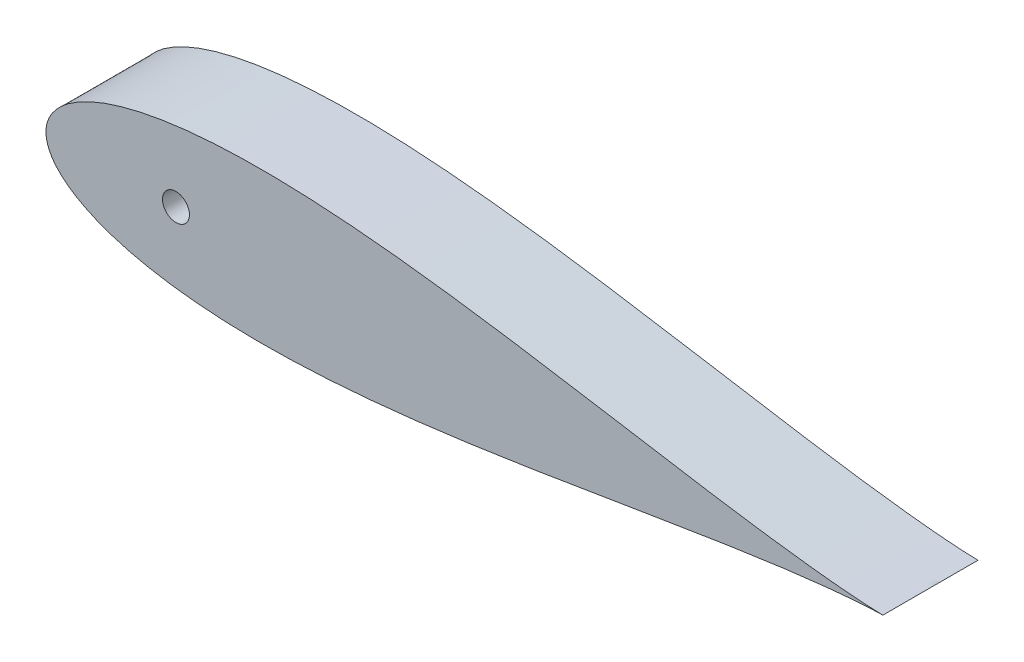
from build123d import *

# Parameters (mm, degrees)
BOSS_EXTRUDE1_DEPTH     = 76.2
SKETCH3_R               = 10.795
CUT_EXTRUDE2_DEPTH      = 76.2
SKETCH6_R               = 6.35
CUT_EXTRUDE3_DEPTH      = 53.34
CUT_EXTRUDE3_DEPTH_BACK = 0.000254
SKETCH7_R               = 1.5875
CUT_EXTRUDE4_DEPTH      = 30.48


with BuildPart() as part:
    # Sketch1 → Boss-Extrude1 (new body)
    with BuildSketch(Plane.XY):
        with BuildLine():
            Line((643.966787522, 0), (643.599082689, 0))
            Line((643.599082689, 0), (643.599082689, -1.016))
            ThreePointArc((643.599082689, -1.016), (643.872033494, -0.540245973), (643.966787522, 0))
        make_face()
        with BuildLine():
            Line((643.599082689, -1.016), (643.599082689, 0))
            Line((643.599082689, 0), (641.567082689, 0))
            ThreePointArc((641.567082689, 0), (642.269121423, -1.135922533), (643.599082689, -1.016))
        make_face()
        with BuildLine():
            Line((641.567082689, 0), (643.599082689, 0))
            Line((643.599082689, 0), (643.966787522, 0))
            ThreePointArc((643.966787522, 0), (643.547407924, 1.075012082), (642.510849283, 1.582039112))
            add(Edge.make_bspline(
                [(642.510849283, 1.582039112), (641.993392355, 1.625070631), (638.093728429, 1.953546407), (630.413817462, 2.663385493), (619.014124193, 3.849253664), (606.374988512, 5.304428983), (592.543922516, 7.037634907), (577.585454095, 9.050636147), (561.564270734, 11.338919625), (544.549749946, 13.890665375), (526.614143658, 16.687720753), (507.832591566, 19.705111663), (488.282710288, 22.911672601), (468.044367735, 26.27043606), (447.199424328, 29.739007432), (425.831595832, 33.270324121), (404.02631566, 36.813220545), (381.870662856, 40.313266856), (359.453314895, 43.713502532), (336.86454415, 46.955447457), (314.196207315, 49.979843895), (291.541767704, 52.727712704), (268.996310773, 55.141201012), (246.65655865, 57.164603829), (224.620860897, 58.745176641), (202.989192599, 59.8341217), (181.863132616, 60.387506142), (161.345829027, 60.366961324), (141.542033828, 59.739895824), (122.558104573, 58.481758104), (104.502313427, 56.574303932), (87.485018636, 54.008935199), (71.619696083, 50.784752003), (57.023709725, 46.912543066), (43.82045433, 42.41500246), (32.141645239, 37.332204029), (22.129107375, 31.731455339), (13.932423524, 25.726412106), (7.689616489, 19.513207632), (3.463136343, 13.420354421), (1.106333228, 7.923389435), (0.154611582, 3.513796615), (0, 1.007496172), (0, 0)],
                knots=[0.020157042, 0.020157042, 0.020157042, 0.020157042, 0.021270888, 0.028552555, 0.036780684, 0.045920102, 0.055931764, 0.066772884, 0.07839713, 0.090754827, 0.103793165, 0.117456432, 0.131686226, 0.146421738, 0.161599998, 0.177156133, 0.193023668, 0.209134786, 0.225420633, 0.241811602, 0.258237647, 0.274628557, 0.290914287, 0.307025229, 0.322892517, 0.338448342, 0.353626207, 0.368361232, 0.382590428, 0.396252961, 0.409290412, 0.42164701, 0.433269881, 0.444109249, 0.45411864, 0.463255055, 0.471479114, 0.478755289, 0.485052318, 0.490344026, 0.494609833, 0.497833231, 0.5, 0.5, 0.5, 0.5], degree=3))
            Line((0, 0), (27.94, 0))
            ThreePointArc((27.94, 0), (40.64, 12.7), (53.34, 0))
            Line((53.34, 0), (93.345, 0))
            ThreePointArc((93.345, 0), (104.14, 10.795), (114.935, 0))
            Line((114.935, 0), (460.660965279, 0))
            Line((460.660965279, 0), (473.360965279, 0))
            Line((473.360965279, 0), (641.567082689, 0))
        make_face()
        with BuildLine():
            ThreePointArc((642.510849283, -1.582039112), (643.111845681, -1.408373102), (643.599082689, -1.016))
            ThreePointArc((643.599082689, -1.016), (642.269121423, -1.135922533), (641.567082689, 0))
            Line((641.567082689, 0), (473.360965279, 0))
            Line((473.360965279, 0), (460.660965279, 0))
            Line((460.660965279, 0), (114.935, 0))
            ThreePointArc((114.935, 0), (104.14, -10.795), (93.345, 0))
            Line((93.345, 0), (53.34, 0))
            ThreePointArc((53.34, 0), (40.64, -12.7), (27.94, 0))
            Line((27.94, 0), (0, 0))
            add(Edge.make_bspline(
                [(0, 0), (0, -1.007496172), (0.154611582, -3.513796615), (1.106333228, -7.923389435), (3.463136343, -13.420354421), (7.689616489, -19.513207632), (13.932423524, -25.726412106), (22.129107375, -31.731455339), (32.141645239, -37.332204029), (43.82045433, -42.41500246), (57.023709725, -46.912543066), (71.619696083, -50.784752003), (87.485018636, -54.008935199), (104.502313427, -56.574303932), (122.558104573, -58.481758104), (141.542033828, -59.739895824), (161.345829027, -60.366961324), (181.863132616, -60.387506142), (202.989192599, -59.8341217), (224.620860897, -58.745176641), (246.65655865, -57.164603829), (268.996310773, -55.141201012), (291.541767704, -52.727712704), (314.196207315, -49.979843895), (336.86454415, -46.955447457), (359.453314895, -43.713502532), (381.870662856, -40.313266856), (404.02631566, -36.813220545), (425.831595832, -33.270324121), (447.199424328, -29.739007432), (468.044367735, -26.27043606), (488.282710288, -22.911672601), (507.832591566, -19.705111663), (526.614143658, -16.687720753), (544.549749946, -13.890665375), (561.564270734, -11.338919625), (577.585454095, -9.050636147), (592.543922516, -7.037634907), (606.374988512, -5.304428983), (619.014124193, -3.849253664), (630.413817462, -2.663385493), (638.093728429, -1.953546407), (641.993392355, -1.625070631), (642.510849283, -1.582039112)],
                knots=[0.5, 0.5, 0.5, 0.5, 0.502166769, 0.505390167, 0.509655974, 0.514947682, 0.521244711, 0.528520886, 0.536744945, 0.54588136, 0.555890751, 0.566730119, 0.57835299, 0.590709588, 0.603747039, 0.617409572, 0.631638768, 0.646373793, 0.661551658, 0.677107483, 0.692974771, 0.709085713, 0.725371443, 0.741762353, 0.758188398, 0.774579367, 0.790865214, 0.806976332, 0.822843867, 0.838400002, 0.853578262, 0.868313774, 0.882543568, 0.896206835, 0.909245173, 0.92160287, 0.933227116, 0.944068236, 0.954079898, 0.963219316, 0.971447445, 0.978729112, 0.979842958, 0.979842958, 0.979842958, 0.979842958], degree=3))
        make_face()
        with BuildLine():
            ThreePointArc((643.966787522, 0), (643.872033494, -0.540245973), (643.599082689, -1.016))
            ThreePointArc((643.599082689, -1.016), (643.111845681, -1.408373102), (642.510849283, -1.582039112))
            add(Edge.make_bspline(
                [(642.510849283, -1.582039112), (644.922074617, -1.381522545), (649.798936594, -1.000308437), (656.504964311, -0.543558383), (662.850933168, -0.234427605), (666.344759683, -0.054696708), (670.56, -0.015678595), (670.56, 0)],
                knots=[0.979842958, 0.979842958, 0.979842958, 0.979842958, 0.985033212, 0.990332793, 0.994605218, 0.997832222, 1, 1, 1, 1], degree=3))
            add(Edge.make_bspline(
                [(670.56, 0), (670.56, 0.015678595), (666.344759683, 0.054696708), (662.850933168, 0.234427605), (656.504964311, 0.543558383), (649.798936594, 1.000308437), (644.922074617, 1.381522545), (642.510849283, 1.582039112)],
                knots=[0, 0, 0, 0, 0.002167778, 0.005394782, 0.009667207, 0.014966788, 0.020157042, 0.020157042, 0.020157042, 0.020157042], degree=3))
            ThreePointArc((642.510849283, 1.582039112), (643.547407924, 1.075012082), (643.966787522, 0))
        make_face()
        with BuildLine():
            ThreePointArc((53.34, 0), (40.64, 12.7), (27.94, 0))
            Line((27.94, 0), (53.34, 0))
        make_face()
        with BuildLine():
            Line((53.34, 0), (27.94, 0))
            ThreePointArc((27.94, 0), (40.64, -12.7), (53.34, 0))
        make_face()
        with BuildLine():
            ThreePointArc((93.345, 0), (104.14, -10.795), (114.935, 0))
            Line((114.935, 0), (93.345, 0))
        make_face()
        with BuildLine():
            Line((93.345, 0), (114.935, 0))
            ThreePointArc((114.935, 0), (104.14, 10.795), (93.345, 0))
        make_face()
    extrude(amount=BOSS_EXTRUDE1_DEPTH)

    # Sketch3 → Cut-Extrude2 (cut)
    with BuildSketch(Plane.XY.offset(76.2)):
        with Locations((104.139232412, 0)):
            Circle(SKETCH3_R)
    extrude(amount=-CUT_EXTRUDE2_DEPTH, mode=Mode.SUBTRACT)

    # Sketch6 → Cut-Extrude3 (cut, two sides)
    with BuildSketch(Plane(origin=(0, 0, 0), x_dir=(0, 0, -1), z_dir=(1, 0, 0))) as cut_extrude3_sk:
        with Locations((-20.32, 0)):
            Circle(SKETCH6_R)
    extrude(amount=CUT_EXTRUDE3_DEPTH, mode=Mode.SUBTRACT)
    extrude(cut_extrude3_sk.sketch, amount=-CUT_EXTRUDE3_DEPTH_BACK, mode=Mode.SUBTRACT)

    # Sketch7 → Cut-Extrude4 (cut)
    with BuildSketch(Plane(origin=(0, 0, 0), x_dir=(-1, 0, 0), z_dir=(0, 0, -1))):
        with Locations((-38.1, 0)):
            Circle(SKETCH7_R)
        with Locations((-50.8, 0)):
            Circle(SKETCH7_R)
    extrude(amount=-CUT_EXTRUDE4_DEPTH, mode=Mode.SUBTRACT)


solid = part.part
